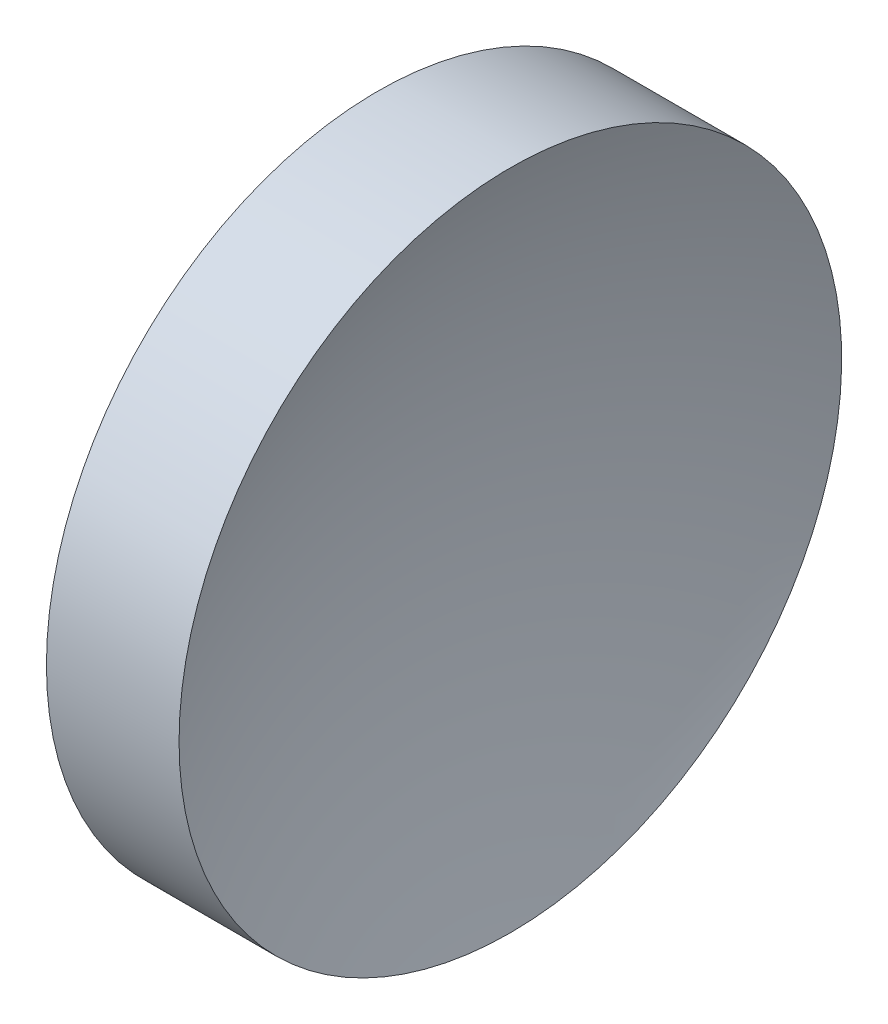
from build123d import *


with BuildPart() as part:
    # 草图1 → 旋转1 (revolve)
    with BuildSketch(Plane.XY, mode=Mode.PRIVATE) as revolve_1_sk:
        with BuildLine():
            Line((119.506834179, 71.193989087), (119.506834179, 83.893989087))
            Line((119.506834179, 83.893989087), (124.590952109, 83.893989087))
            ThreePointArc((124.590952109, 83.893989087), (122.659415388, 77.674106089), (122.006834179, 71.193989087))
            Line((122.006834179, 71.193989087), (119.506834179, 71.193989087))
        make_face()
    revolve(revolve_1_sk.sketch.rotate(Axis((111.955229758, 71.193989087, 0), (1, 0, 0)), 180), axis=Axis((111.955229758, 71.193989087, 0), (1, 0, 0)))  # turned: the seam where the file's is


solid = part.part
